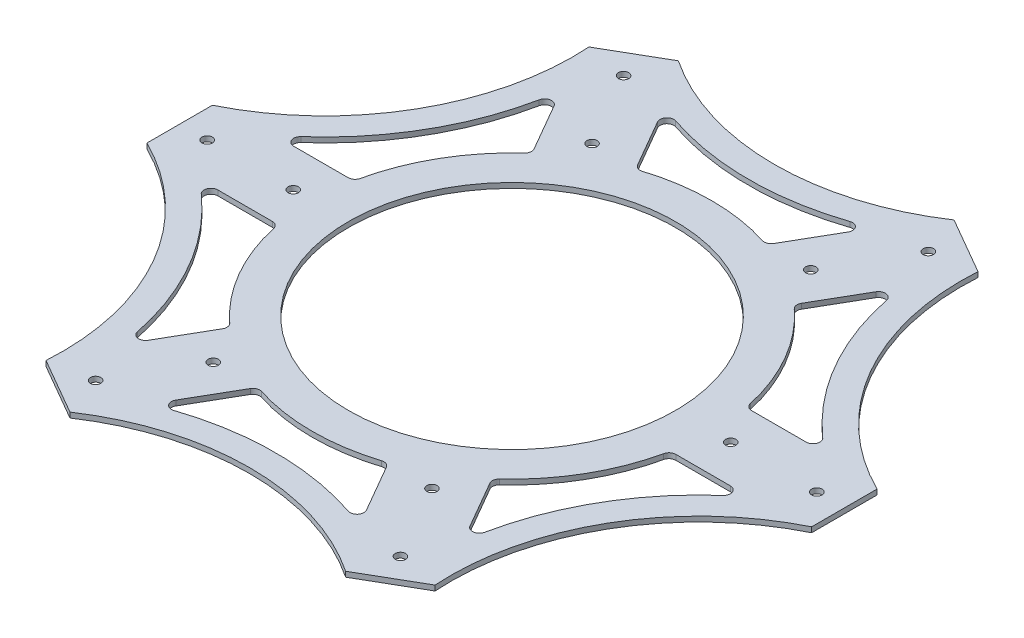
from build123d import *

# Parameters (mm, degrees)
EXTRUDE_1_DEPTH = 1.5


with BuildPart() as part:
    # Эскиз1 → Бобышка-Вытянуть1 (new body)
    with BuildSketch(Plane(origin=(0, 0, 0), x_dir=(1, 0, 0), z_dir=(0, 1, 0))):
        with BuildLine():
            Line((-40.022758664, 88.321451465), (-48.25, 83.571451465))
            Line((-48.25, 83.571451465), (-56.477241336, 78.821451465))
            ThreePointArc((-56.477241336, 78.821451465), (-65.99206702, 38.100537658), (-96.5, 9.5))
            Line((-96.5, 9.5), (-96.5, 0))
            Line((-96.5, 0), (-96.5, -9.5))
            ThreePointArc((-96.5, -9.5), (-65.99206702, -38.100537658), (-56.477241336, -78.821451465))
            Line((-56.477241336, -78.821451465), (-48.25, -83.571451465))
            Line((-48.25, -83.571451465), (-40.022758664, -88.321451465))
            ThreePointArc((-40.022758664, -88.321451465), (0, -76.201075317), (40.022758664, -88.321451465))
            Line((40.022758664, -88.321451465), (48.25, -83.571451465))
            Line((48.25, -83.571451465), (56.477241336, -78.821451465))
            ThreePointArc((56.477241336, -78.821451465), (65.99206702, -38.100537658), (96.5, -9.5))
            Line((96.5, -9.5), (96.5, 0))
            Line((96.5, 0), (96.5, 9.5))
            ThreePointArc((96.5, 9.5), (65.99206702, 38.100537658), (56.477241336, 78.821451465))
            Line((56.477241336, 78.821451465), (48.25, 83.571451465))
            Line((48.25, 83.571451465), (40.022758664, 88.321451465))
            ThreePointArc((40.022758664, 88.321451465), (0, 76.201075317), (-40.022758664, 88.321451465))
        make_face()
        with BuildLine():
            Line((27.673728715, 69.932304169), (19.76108985, 56.227211632))
            ThreePointArc((19.76108985, 56.227211632), (18.754131872, 55.363280199), (17.428071074, 55.319637911))
            ThreePointArc((17.428071074, 55.319637911), (0, 58), (-17.428071074, 55.319637911))
            ThreePointArc((-17.428071074, 55.319637911), (-18.754131872, 55.363280199), (-19.76108985, 56.227211632))
            Line((-19.76108985, 56.227211632), (-27.673728715, 69.932304169))
            ThreePointArc((-27.673728715, 69.932304169), (-27.490161024, 72.198084576), (-25.306162986, 72.828648227))
            ThreePointArc((-25.306162986, 72.828648227), (0, 68.701075317), (25.306162986, 72.828648227))
            ThreePointArc((25.306162986, 72.828648227), (27.490161024, 72.198084576), (27.673728715, 69.932304169))
        make_face(mode=Mode.SUBTRACT)
        with BuildLine():
            Line((-46.726287598, 58.932304169), (-38.813648733, 45.227211632))
            ThreePointArc((-38.813648733, 45.227211632), (-38.568941153, 43.923194727), (-39.194176222, 42.752971245))
            ThreePointArc((-39.194176222, 42.752971245), (-50.229473419, 29), (-56.622247296, 12.566666667))
            ThreePointArc((-56.622247296, 12.566666667), (-57.323073025, 11.440085472), (-58.574738582, 11))
            Line((-58.574738582, 11), (-74.400016313, 11))
            ThreePointArc((-74.400016313, 11), (-76.270455859, 12.291864487), (-75.724540981, 14.498544095))
            ThreePointArc((-75.724540981, 14.498544095), (-59.496876492, 34.350537658), (-50.418377995, 58.330104132))
            ThreePointArc((-50.418377995, 58.330104132), (-48.780294835, 59.906220089), (-46.726287598, 58.932304169))
        make_face(mode=Mode.SUBTRACT)
        with BuildLine():
            Line((74.400016313, 11), (58.574738582, 11))
            ThreePointArc((58.574738582, 11), (57.323073025, 11.440085472), (56.622247296, 12.566666667))
            ThreePointArc((56.622247296, 12.566666667), (50.229473419, 29), (39.194176222, 42.752971245))
            ThreePointArc((39.194176222, 42.752971245), (38.568941153, 43.923194727), (38.813648733, 45.227211632))
            Line((38.813648733, 45.227211632), (46.726287598, 58.932304169))
            ThreePointArc((46.726287598, 58.932304169), (48.780294835, 59.906220089), (50.418377995, 58.330104132))
            ThreePointArc((50.418377995, 58.330104132), (59.496876492, 34.350537658), (75.724540981, 14.498544095))
            ThreePointArc((75.724540981, 14.498544095), (76.270455859, 12.291864487), (74.400016313, 11))
        make_face(mode=Mode.SUBTRACT)
        with BuildLine():
            Line((46.726287598, -58.932304169), (38.813648733, -45.227211632))
            ThreePointArc((38.813648733, -45.227211632), (38.568941153, -43.923194727), (39.194176222, -42.752971245))
            ThreePointArc((39.194176222, -42.752971245), (50.229473419, -29), (56.622247296, -12.566666667))
            ThreePointArc((56.622247296, -12.566666667), (57.323073025, -11.440085472), (58.574738582, -11))
            Line((58.574738582, -11), (74.400016313, -11))
            ThreePointArc((74.400016313, -11), (76.270455859, -12.291864487), (75.724540981, -14.498544095))
            ThreePointArc((75.724540981, -14.498544095), (59.496876492, -34.350537658), (50.418377995, -58.330104132))
            ThreePointArc((50.418377995, -58.330104132), (48.780294835, -59.906220089), (46.726287598, -58.932304169))
        make_face(mode=Mode.SUBTRACT)
        with BuildLine():
            Line((-27.673728715, -69.932304169), (-19.76108985, -56.227211632))
            ThreePointArc((-19.76108985, -56.227211632), (-18.754131872, -55.363280199), (-17.428071074, -55.319637911))
            ThreePointArc((-17.428071074, -55.319637911), (0, -58), (17.428071074, -55.319637911))
            ThreePointArc((17.428071074, -55.319637911), (18.754131872, -55.363280199), (19.76108985, -56.227211632))
            Line((19.76108985, -56.227211632), (27.673728715, -69.932304169))
            ThreePointArc((27.673728715, -69.932304169), (27.490161024, -72.198084576), (25.306162986, -72.828648227))
            ThreePointArc((25.306162986, -72.828648227), (0, -68.701075317), (-25.306162986, -72.828648227))
            ThreePointArc((-25.306162986, -72.828648227), (-27.490161024, -72.198084576), (-27.673728715, -69.932304169))
        make_face(mode=Mode.SUBTRACT)
        with BuildLine():
            Line((-74.400016313, -11), (-58.574738582, -11))
            ThreePointArc((-58.574738582, -11), (-57.323073025, -11.440085472), (-56.622247296, -12.566666667))
            ThreePointArc((-56.622247296, -12.566666667), (-50.229473419, -29), (-39.194176222, -42.752971245))
            ThreePointArc((-39.194176222, -42.752971245), (-38.568941153, -43.923194727), (-38.813648733, -45.227211632))
            Line((-38.813648733, -45.227211632), (-46.726287598, -58.932304169))
            ThreePointArc((-46.726287598, -58.932304169), (-48.780294835, -59.906220089), (-50.418377995, -58.330104132))
            ThreePointArc((-50.418377995, -58.330104132), (-59.496876492, -34.350537658), (-75.724540981, -14.498544095))
            ThreePointArc((-75.724540981, -14.498544095), (-76.270455859, -12.291864487), (-74.400016313, -11))
        make_face(mode=Mode.SUBTRACT)
        with BuildLine():
            ThreePointArc((-23.75, 41.13620668), (-41.13620668, 23.75), (-47.5, 0))
            ThreePointArc((-47.5, 0), (-41.13620668, -23.75), (-23.75, -41.13620668))
            ThreePointArc((-23.75, -41.13620668), (0, -47.5), (23.75, -41.13620668))
            ThreePointArc((23.75, -41.13620668), (41.13620668, -23.75), (47.5, 0))
            ThreePointArc((47.5, 0), (41.13620668, 23.75), (23.75, 41.13620668))
            ThreePointArc((23.75, 41.13620668), (0, 47.5), (-23.75, 41.13620668))
        make_face(mode=Mode.SUBTRACT)
        with BuildLine():
            ThreePointArc((-87, 0), (-88.5, 1.5), (-90, 0))
            ThreePointArc((-90, 0), (-88.5, -1.5), (-87, 0))
        make_face(mode=Mode.SUBTRACT)
        with BuildLine():
            ThreePointArc((-62, 0), (-63.5, 1.5), (-65, 0))
            ThreePointArc((-65, 0), (-63.5, -1.5), (-62, 0))
        make_face(mode=Mode.SUBTRACT)
        with BuildLine():
            ThreePointArc((-32.5, 56.291651246), (-33.049038106, 54.24261314), (-31, 53.693575035))
            ThreePointArc((-31, 53.693575035), (-30.450961894, 55.74261314), (-32.5, 56.291651246))
        make_face(mode=Mode.SUBTRACT)
        with BuildLine():
            ThreePointArc((-45, 77.942286341), (-45.549038106, 75.893248235), (-43.5, 75.344210129))
            ThreePointArc((-43.5, 75.344210129), (-42.950961894, 77.393248235), (-45, 77.942286341))
        make_face(mode=Mode.SUBTRACT)
        with BuildLine():
            ThreePointArc((32.5, 56.291651246), (30.450961894, 55.74261314), (31, 53.693575035))
            ThreePointArc((31, 53.693575035), (33.049038106, 54.24261314), (32.5, 56.291651246))
        make_face(mode=Mode.SUBTRACT)
        with BuildLine():
            ThreePointArc((45, 77.942286341), (42.950961894, 77.393248235), (43.5, 75.344210129))
            ThreePointArc((43.5, 75.344210129), (45.549038106, 75.893248235), (45, 77.942286341))
        make_face(mode=Mode.SUBTRACT)
        with BuildLine():
            ThreePointArc((65, 0), (63.5, 1.5), (62, 0))
            ThreePointArc((62, 0), (63.5, -1.5), (65, 0))
        make_face(mode=Mode.SUBTRACT)
        with BuildLine():
            ThreePointArc((90, 0), (88.5, 1.5), (87, 0))
            ThreePointArc((87, 0), (88.5, -1.5), (90, 0))
        make_face(mode=Mode.SUBTRACT)
        with BuildLine():
            ThreePointArc((32.5, -56.291651246), (33.049038106, -54.24261314), (31, -53.693575035))
            ThreePointArc((31, -53.693575035), (30.450961894, -55.74261314), (32.5, -56.291651246))
        make_face(mode=Mode.SUBTRACT)
        with BuildLine():
            ThreePointArc((45, -77.942286341), (45.549038106, -75.893248235), (43.5, -75.344210129))
            ThreePointArc((43.5, -75.344210129), (42.950961894, -77.393248235), (45, -77.942286341))
        make_face(mode=Mode.SUBTRACT)
        with BuildLine():
            ThreePointArc((-32.5, -56.291651246), (-30.450961894, -55.74261314), (-31, -53.693575035))
            ThreePointArc((-31, -53.693575035), (-33.049038106, -54.24261314), (-32.5, -56.291651246))
        make_face(mode=Mode.SUBTRACT)
        with BuildLine():
            ThreePointArc((-45, -77.942286341), (-42.950961894, -77.393248235), (-43.5, -75.344210129))
            ThreePointArc((-43.5, -75.344210129), (-45.549038106, -75.893248235), (-45, -77.942286341))
        make_face(mode=Mode.SUBTRACT)
    extrude(amount=EXTRUDE_1_DEPTH)


solid = part.part
